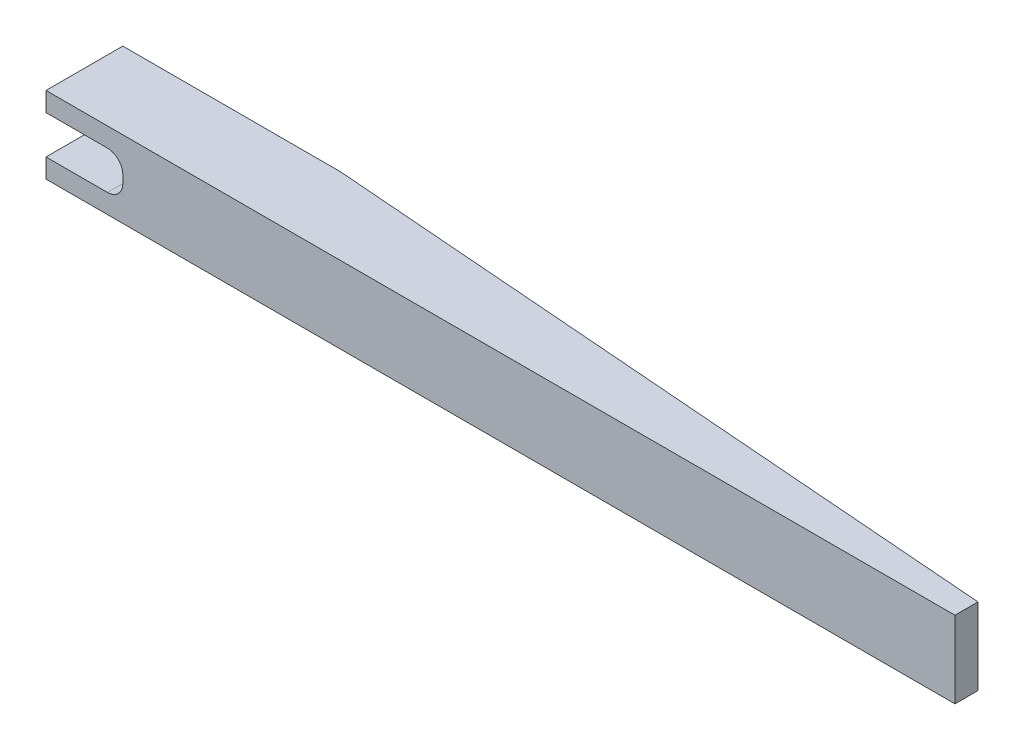
from build123d import *

# Parameters (mm, degrees)
CROQUIS1_W              = 118.35
CROQUIS1_H              = 10
SALIENTE_EXTRUIR1_DEPTH = 10
CROQUIS2_W              = 20
CROQUIS2_H              = 5
CORTAR_EXTRUIR1_DEPTH   = 11
CORTAR_EXTRUIR2_DEPTH   = 11
REDONDEO1_R             = 2


with BuildPart() as part:
    # Croquis1 → Saliente-Extruir1 (new body)
    with BuildSketch(Plane.XY):
        Rectangle(CROQUIS1_W, CROQUIS1_H)
    extrude(amount=SALIENTE_EXTRUIR1_DEPTH)

    # Croquis2 → Cortar-Extruir1 (cut, through all)
    with BuildSketch(Plane.XY.offset(10)):
        with Locations((-59.175, 0)):
            Rectangle(CROQUIS2_W, CROQUIS2_H)
    extrude(amount=-CORTAR_EXTRUIR1_DEPTH, mode=Mode.SUBTRACT)

    # Croquis3 → Cortar-Extruir2 (cut, through all)
    with BuildSketch(Plane(origin=(0, 5, 0), x_dir=(1, 0, 0), z_dir=(0, 1, 0))):
        Polygon((59.175, -7), (-30.825, 0), (59.175, 0), align=None)
    extrude(amount=-CORTAR_EXTRUIR2_DEPTH, mode=Mode.SUBTRACT)

    # Redondeo1
    redondeo1_edges = [part.edges().sort_by_distance(p)[0] for p in [
        (-49.175, -2.5, 5),
        (-49.175, 2.5, 5),
    ]]
    fillet(redondeo1_edges, radius=REDONDEO1_R)


solid = part.part
